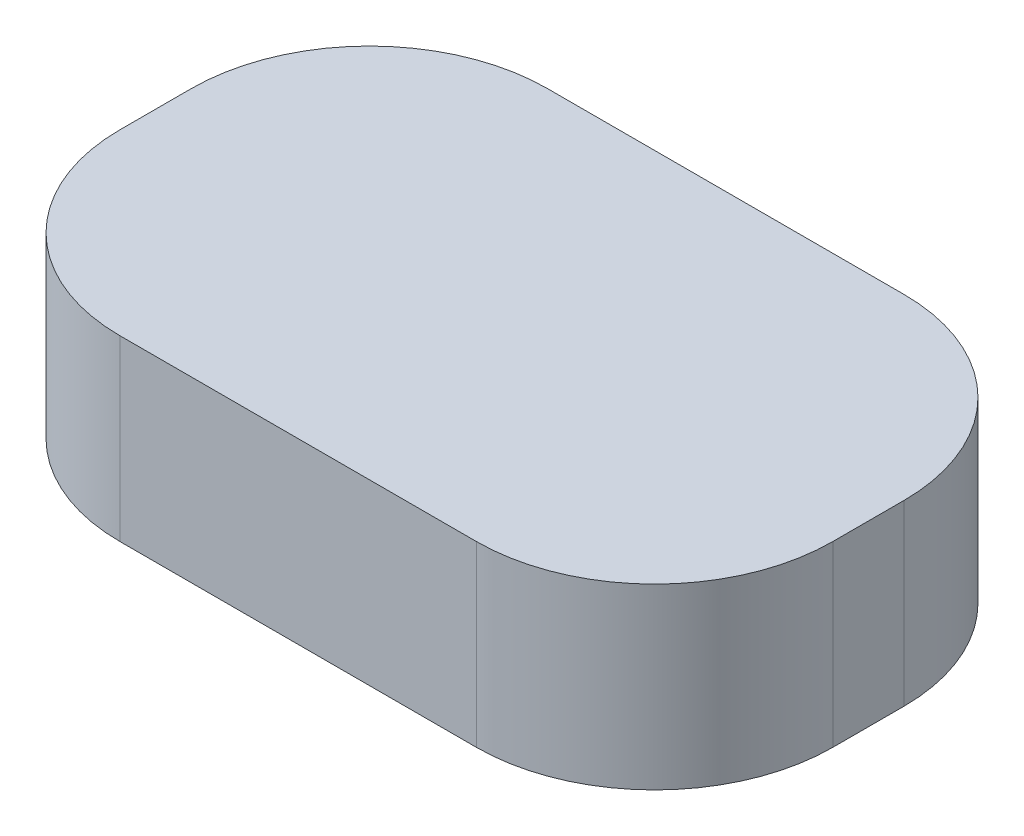
from build123d import *

# Parameters (mm, degrees)
BOSS_EXTRUDE1_DEPTH = 5


with BuildPart() as part:
    # Sketch1 → Boss-Extrude1 (new body)
    with BuildSketch(Plane(origin=(0, 0, 0), x_dir=(1, 0, 0), z_dir=(0, 1, 0))):
        with BuildLine():
            Line((5, 0), (15, 0))
            ThreePointArc((15, 0), (18.535533906, -1.464466094), (20, -5))
            Line((20, -5), (20, -7))
            ThreePointArc((20, -7), (18.535533906, -10.535533906), (15, -12))
            Line((15, -12), (5, -12))
            ThreePointArc((5, -12), (1.464466094, -10.535533906), (0, -7))
            Line((0, -7), (0, -5))
            ThreePointArc((0, -5), (1.464466094, -1.464466094), (5, 0))
        make_face()
    extrude(amount=BOSS_EXTRUDE1_DEPTH)


solid = part.part
